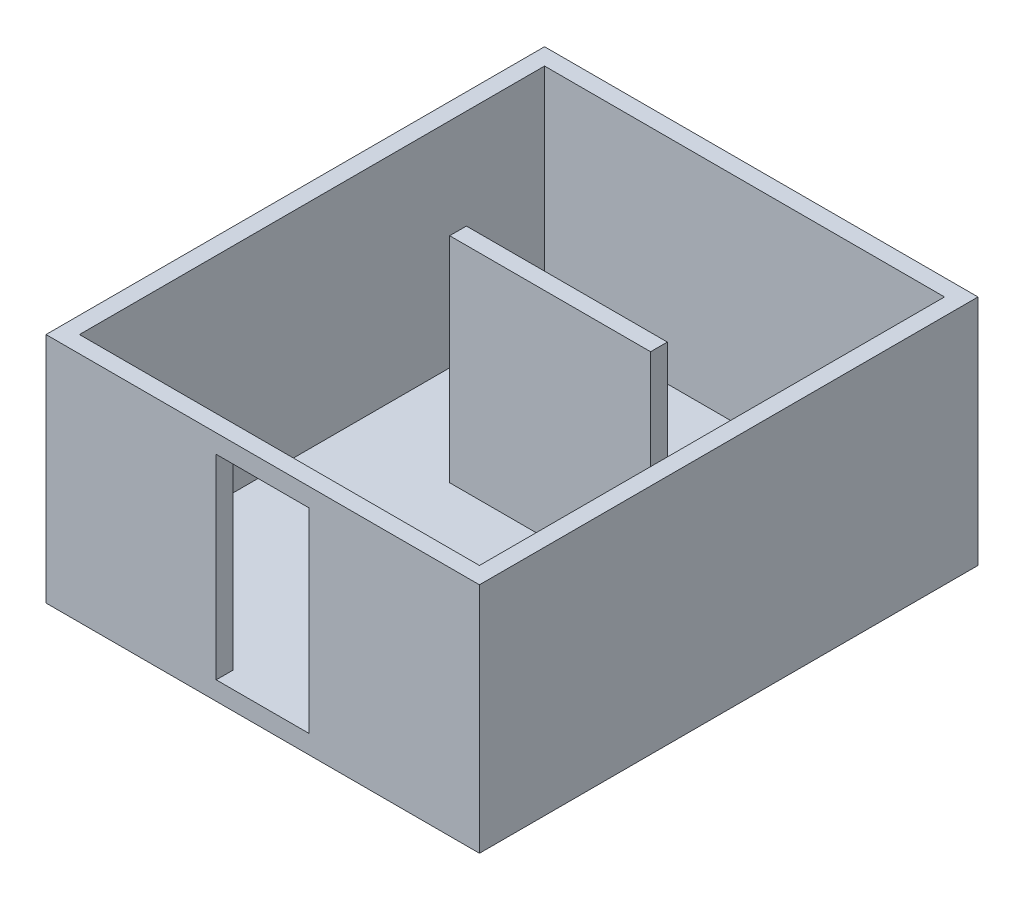
from build123d import *

# Parameters (mm, degrees)
CROQUIS1_W              = 4660
CROQUIS1_H              = 5360
SALIENTE_EXTRUIR1_DEPTH = 200
CROQUIS2_W              = 4660
CROQUIS2_H              = 5360
CROQUIS2_W_2            = 4300
CROQUIS2_H_2            = 5000
CROQUIS2_W_3            = 2160
CROQUIS2_H_3            = 180
SALIENTE_EXTRUIR2_DEPTH = 2300
CROQUIS3_W              = 1000
CROQUIS3_H              = 2100
CORTAR_EXTRUIR1_DEPTH   = 180


with BuildPart() as part:
    # Croquis1 → Saliente-Extruir1 (new body)
    with BuildSketch(Plane(origin=(0, 0, 0), x_dir=(1, 0, 0), z_dir=(0, 1, 0))):
        with Locations((2330, -2680)):
            Rectangle(CROQUIS1_W, CROQUIS1_H)
    extrude(amount=SALIENTE_EXTRUIR1_DEPTH)

    # Croquis2 → Saliente-Extruir2 (add)
    with BuildSketch(Plane(origin=(0, 200, 0), x_dir=(1, 0, 0), z_dir=(0, 1, 0))):
        with Locations((2330, -2680)):
            Rectangle(CROQUIS2_W, CROQUIS2_H)
        with Locations((2330, -2680)):
            Rectangle(CROQUIS2_W_2, CROQUIS2_H_2, mode=Mode.SUBTRACT)
        with Locations((2330, -2180)):
            Rectangle(CROQUIS2_W_3, CROQUIS2_H_3)
    extrude(amount=SALIENTE_EXTRUIR2_DEPTH)

    # Croquis3 → Cortar-Extruir1 (cut)
    with BuildSketch(Plane.XY.offset(5360)):
        with Locations((2330, 1250)):
            Rectangle(CROQUIS3_W, CROQUIS3_H)
    extrude(amount=-CORTAR_EXTRUIR1_DEPTH, mode=Mode.SUBTRACT)


solid = part.part
